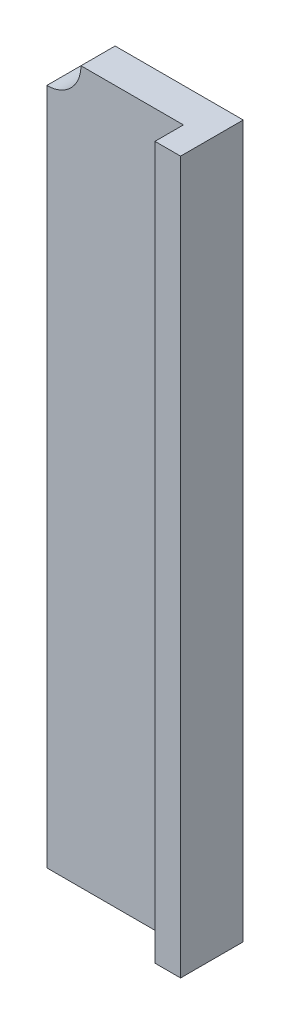
from build123d import *

# Parameters (mm, degrees)
CROQUIS1_W              = 28.5
CROQUIS1_H              = 125
SALIENTE_EXTRUIR1_DEPTH = 6
CROQUIS2_W              = 4.5
CROQUIS2_H              = 125
SALIENTE_EXTRUIR2_DEPTH = 5
CROQUIS3_R              = 6
CORTAR_EXTRUIR1_DEPTH   = 7


with BuildPart() as part:
    # Croquis1 → Saliente-Extruir1 (new body)
    with BuildSketch(Plane.XY):
        with Locations((14.25, 62.5)):
            Rectangle(CROQUIS1_W, CROQUIS1_H)
    extrude(amount=SALIENTE_EXTRUIR1_DEPTH)

    # Croquis2 → Saliente-Extruir2 (add)
    with BuildSketch(Plane.XY.offset(6)):
        with Locations((26.25, 62.5)):
            Rectangle(CROQUIS2_W, CROQUIS2_H)
    extrude(amount=SALIENTE_EXTRUIR2_DEPTH)

    # Croquis3 → Cortar-Extruir1 (cut, through all)
    with BuildSketch(Plane.XY.offset(6)):
        with Locations((0, 125)):
            Circle(CROQUIS3_R)
    extrude(amount=-CORTAR_EXTRUIR1_DEPTH, mode=Mode.SUBTRACT)


solid = part.part
